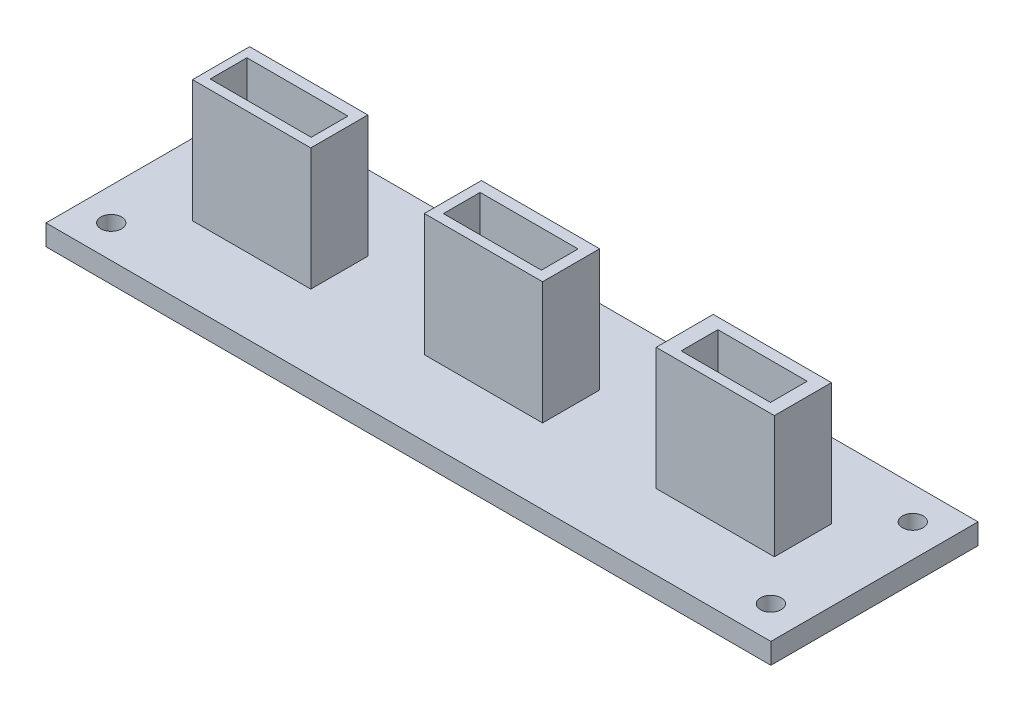
from build123d import *

# Parameters (mm, degrees)
SKETCH1_W           = 88.9
SKETCH1_H           = 25.4
BOSS_EXTRUDE1_DEPTH = 2.54
SKETCH2_R           = 1.27
CUT_EXTRUDE1_DEPTH  = 2.54
SKETCH16_W          = 14.499999956
SKETCH16_H          = 6.99999997
BOSS_EXTRUDE3_DEPTH = 14.999999972
SKETCH17_W          = 12.390836481
SKETCH17_H          = 4.505758721
SKETCH17_W_2        = 12.015356588
SKETCH17_W_3        = 10.95149689
CUT_EXTRUDE4_DEPTH  = 12.459999972
SKETCH18_R          = 0.865438392
SKETCH18_R_2        = 0.972006337
SKETCH18_R_3        = 0.938699733
SKETCH18_R_4        = 1.023043952
SKETCH18_R_5        = 0.699865796
SKETCH18_R_6        = 0.72485584
SKETCH18_R_7        = 0.753208606
SKETCH18_R_8        = 0.89391984
SKETCH18_R_9        = 0.684371717
SKETCH18_R_10       = 0.906595882
SKETCH18_R_11       = 0.774291856
SKETCH18_R_12       = 0.739788643
CUT_EXTRUDE5_DEPTH  = 12.459999972


with BuildPart() as part:
    # Sketch1 → Boss-Extrude1 (new body)
    with BuildSketch(Plane(origin=(0, 0, 0), x_dir=(1, 0, 0), z_dir=(0, 1, 0))):
        Rectangle(SKETCH1_W, SKETCH1_H)
    extrude(amount=BOSS_EXTRUDE1_DEPTH)

    # Sketch2 → Cut-Extrude1 (cut)
    with BuildSketch(Plane(origin=(0, 2.54, 0), x_dir=(1, 0, 0), z_dir=(0, 1, 0))):
        with Locations((-40.45, 8.7)):
            Circle(SKETCH2_R)
        with Locations((-40.45, -8.7)):
            Circle(SKETCH2_R)
        with Locations((40.45, -8.7)):
            Circle(SKETCH2_R)
        with Locations((40.45, 8.7)):
            Circle(SKETCH2_R)
    extrude(amount=-CUT_EXTRUDE1_DEPTH, mode=Mode.SUBTRACT)

    # Sketch16 → Boss-Extrude3 (add)
    with BuildSketch(Plane(origin=(0, 2.54, 0), x_dir=(1, 0, 0), z_dir=(0, 1, 0))):
        Rectangle(SKETCH16_W, SKETCH16_H)
        with Locations((28.430000036, 1.27e-07)):
            Rectangle(SKETCH16_W, SKETCH16_H)
        with Locations((-28.430000036, 1.27e-07)):
            Rectangle(SKETCH16_W, SKETCH16_H)
    extrude(amount=BOSS_EXTRUDE3_DEPTH)

    # Sketch17 → Cut-Extrude4 (cut)
    with BuildSketch(Plane(origin=(0, 17.539999972, 0), x_dir=(1, 0, 0), z_dir=(0, 1, 0))):
        with Locations((-28.473891916, -0.093869973)):
            Rectangle(SKETCH17_W, SKETCH17_H)
        with Locations((-0.062579982, -0.093869973)):
            Rectangle(SKETCH17_W_2, SKETCH17_H)
        with Locations((28.567761889, -0.093869973)):
            Rectangle(SKETCH17_W_3, SKETCH17_H)
    extrude(amount=-CUT_EXTRUDE4_DEPTH, mode=Mode.SUBTRACT)

    # Sketch18 → Cut-Extrude5 (cut)
    with BuildSketch(Plane(origin=(0, 5.08, 0), x_dir=(1, 0, 0), z_dir=(0, 1, 0))):
        with Locations((-33.35513053, 0)):
            Circle(SKETCH18_R)
        with Locations((-30.2887114, 0)):
            Circle(SKETCH18_R_2)
        with Locations((-27.535192182, 0)):
            Circle(SKETCH18_R_3)
        with Locations((-24.906832928, 0)):
            Circle(SKETCH18_R_4)
        with Locations((-4.506191176, -1.023043952)):
            Circle(SKETCH18_R_5)
        with Locations((-1.873685579, -1.023043952)):
            Circle(SKETCH18_R_6)
        with Locations((0.727684736, -1.023043952)):
            Circle(SKETCH18_R_7)
        with Locations((3.790367697, -1.023043952)):
            Circle(SKETCH18_R_8)
        with Locations((25.783303286, -1.023043952)):
            Circle(SKETCH18_R_9)
        with Locations((28.074005802, -1.023043952)):
            Circle(SKETCH18_R_10)
        with Locations((30.354212641, -1.023043952)):
            Circle(SKETCH18_R_11)
        with Locations((32.413417846, -1.023043952)):
            Circle(SKETCH18_R_12)
    extrude(amount=-CUT_EXTRUDE5_DEPTH, mode=Mode.SUBTRACT)


solid = part.part
